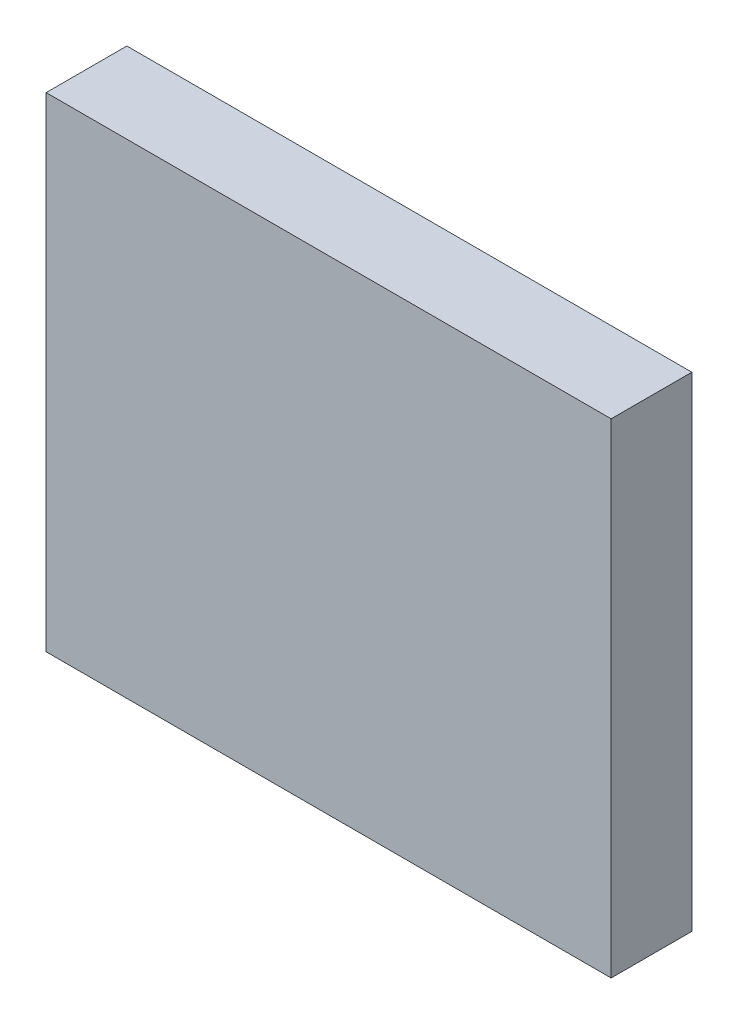
from build123d import *

# Parameters (mm, degrees)
SKETCH1_W           = 28
SKETCH1_H           = 24
BOSS_EXTRUDE1_DEPTH = 4


with BuildPart() as part:
    # Sketch1 → Boss-Extrude1 (new body)
    with BuildSketch(Plane.XY):
        Rectangle(SKETCH1_W, SKETCH1_H)
    extrude(amount=BOSS_EXTRUDE1_DEPTH)


solid = part.part
